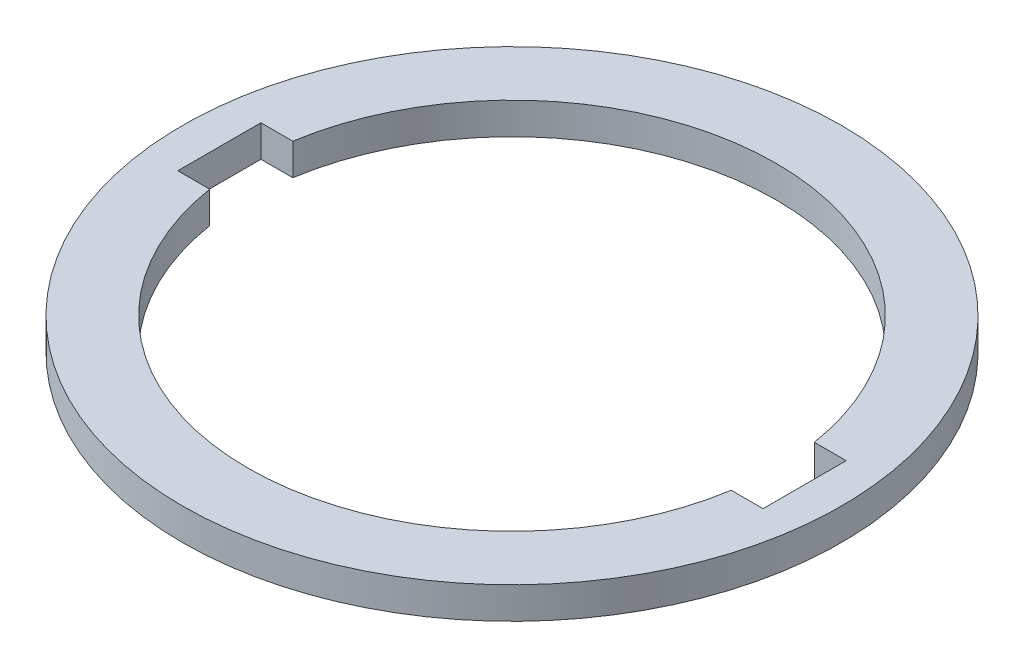
from build123d import *

# Parameters (mm, degrees)
SKETCH2_R           = 49.55
SKETCH2_R_2         = 39.7
BOSS_EXTRUDE1_DEPTH = 4.7625
SKETCH3_W           = 88
SKETCH3_H           = 12.5
CUT_EXTRUDE1_DEPTH  = 5.7625


with BuildPart() as part:
    # Sketch2 → Boss-Extrude1 (new body)
    with BuildSketch(Plane(origin=(0, 0, 0), x_dir=(1, 0, 0), z_dir=(0, 1, 0))):
        Circle(SKETCH2_R)
        Circle(SKETCH2_R_2, mode=Mode.SUBTRACT)
    extrude(amount=BOSS_EXTRUDE1_DEPTH)

    # Sketch3 → Cut-Extrude1 (cut, through all)
    with BuildSketch(Plane(origin=(0, 4.7625, 0), x_dir=(1, 0, 0), z_dir=(0, 1, 0))):
        Rectangle(SKETCH3_W, SKETCH3_H)
    extrude(amount=-CUT_EXTRUDE1_DEPTH, mode=Mode.SUBTRACT)


solid = part.part
